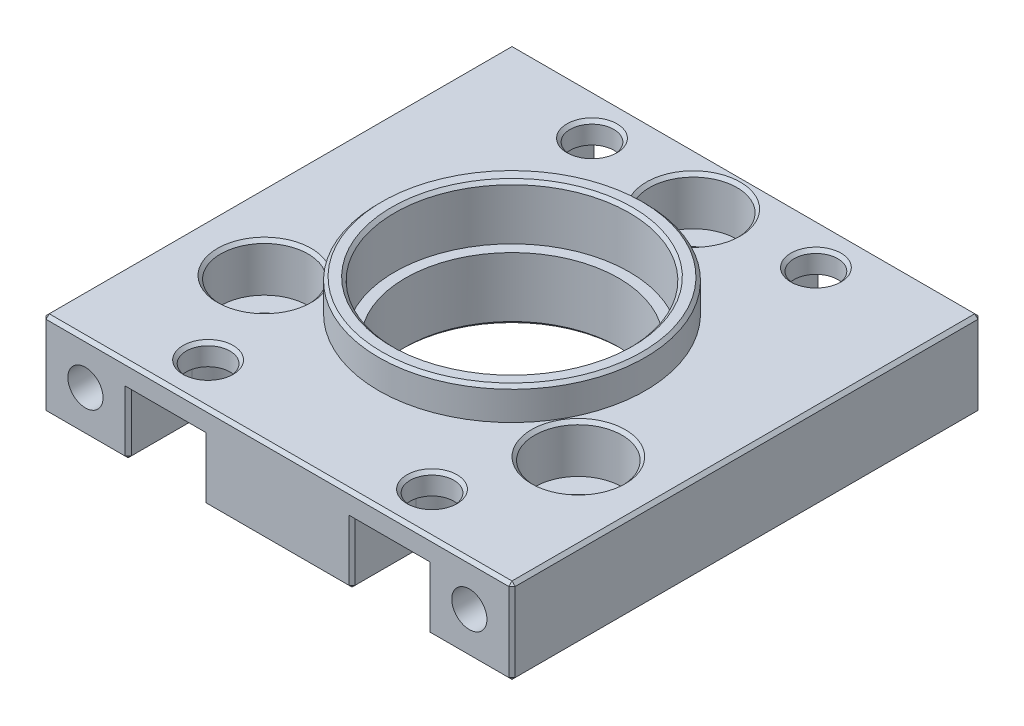
from build123d import *

# Parameters (mm, degrees)
SKETCH1_W                      = 44
SKETCH1_H                      = 44
SKETCH1_R                      = 2.05
SKETCH1_R_2                    = 10
BOSS_EXTRUDE1_DEPTH            = 5.5
SKETCH3_R                      = 11
CUT_EXTRUDE1_DEPTH             = 5.1
M4X0_7_TAPPED_HOLE1_AT_2_COUNT = 2
M4X0_7_TAPPED_HOLE1_AT_2_PITCH = 36
SKETCH6_R                      = 4.1
CUT_EXTRUDE2_DEPTH             = 7.5
SKETCH7_W                      = 44
SKETCH7_H                      = 44
SKETCH7_R                      = 12.5
SKETCH7_R_2                    = 4.1
CUT_EXTRUDE3_DEPTH             = 3
CUT_EXTRUDE_1_DEPTH            = 6
SKETCH_2_R                     = 2.05
CUT_EXTRUDE_2_DEPTH            = 5
CHAMFER_1_SIZE                 = 0.3


with BuildPart() as part:
    # Sketch1 → Boss-Extrude1 (new body, symmetric)
    with BuildSketch(Plane(origin=(0, 0, 0), x_dir=(1, 0, 0), z_dir=(0, 1, 0))):
        Rectangle(SKETCH1_W, SKETCH1_H)
        with Locations((0, 17)):
            Circle(SKETCH1_R, mode=Mode.SUBTRACT)
        with Locations((14.722431864, -8.5)):
            Circle(SKETCH1_R, mode=Mode.SUBTRACT)
        with Locations((-14.722431864, -8.5)):
            Circle(SKETCH1_R, mode=Mode.SUBTRACT)
        Circle(SKETCH1_R_2, mode=Mode.SUBTRACT)
    extrude(amount=BOSS_EXTRUDE1_DEPTH, both=True)

    # Sketch3 → Cut-Extrude1 (cut)
    with BuildSketch(Plane(origin=(0, 5.5, 0), x_dir=(1, 0, 0), z_dir=(0, 1, 0))):
        Circle(SKETCH3_R)
    extrude(amount=-CUT_EXTRUDE1_DEPTH, mode=Mode.SUBTRACT)

    # Sketch5 → M4x0.7 Tapped Hole1 (revolve, cut)
    with BuildSketch(Plane(origin=(-18, -1.5, -22), x_dir=(0, 1, 0), z_dir=(1, 0, 0))):
        Polygon((0, 0), (0, 7.991420021), (1.65, 7), (1.65, 0), align=None)
    m4x0_7_tapped_hole1 = revolve(axis=Axis((-18, -1.5, -28.35), (0, 0, 1)), mode=Mode.SUBTRACT)

    # M4x0.7 Tapped Hole1 at 2: M4x0.7 Tapped Hole1 ×2
    with Locations(*[(i * M4X0_7_TAPPED_HOLE1_AT_2_PITCH, 0, 0) for i in range(1, M4X0_7_TAPPED_HOLE1_AT_2_COUNT)]):
        add(m4x0_7_tapped_hole1, mode=Mode.SUBTRACT)

    # Mirror1: M4x0.7 Tapped Hole1 across plane
    add(m4x0_7_tapped_hole1.mirror(Plane.XY), mode=Mode.SUBTRACT)

    # Mirror1 copy 1 sketch → Mirror1 copy 1 (revolve, cut)
    with BuildSketch(Plane(origin=(18, -1.5, 22), x_dir=(0, 1, 0), z_dir=(1, 0, 0))):
        Polygon((0, 0), (0, -7.991420021), (1.65, -7), (1.65, 0), align=None)
    revolve(axis=Axis((18, -1.5, 28.35), (0, 0, 1)), mode=Mode.SUBTRACT)

    # Sketch6 → Cut-Extrude2 (cut)
    with BuildSketch(Plane(origin=(0, 5.5, 0), x_dir=(1, 0, 0), z_dir=(0, 1, 0))):
        with Locations((-14.722431864, -8.5)):
            Circle(SKETCH6_R)
        with Locations((0, 17)):
            Circle(SKETCH6_R)
        with Locations((14.722431864, -8.5)):
            Circle(SKETCH6_R)
    extrude(amount=-CUT_EXTRUDE2_DEPTH, mode=Mode.SUBTRACT)

    # Sketch7 → Cut-Extrude3 (cut)
    with BuildSketch(Plane(origin=(0, 5.5, 0), x_dir=(1, 0, 0), z_dir=(0, 1, 0))):
        Rectangle(SKETCH7_W, SKETCH7_H)
        Circle(SKETCH7_R, mode=Mode.SUBTRACT)
        with Locations((14.722431864, -8.5)):
            Circle(SKETCH7_R_2, mode=Mode.SUBTRACT)
        with Locations((0, 17)):
            Circle(SKETCH7_R_2, mode=Mode.SUBTRACT)
        with Locations((-14.722431864, -8.5)):
            Circle(SKETCH7_R_2, mode=Mode.SUBTRACT)
    extrude(amount=-CUT_EXTRUDE3_DEPTH, mode=Mode.SUBTRACT)

    # 草图1 → 切除-拉伸1 (cut)
    with BuildSketch(Plane.XZ.offset(5.5)):
        with BuildLine():
            Line((7, -36), (7, -16))
            ThreePointArc((7, -16), (10.5, -12.5), (14, -16))
            Line((14, -16), (14, -36))
            ThreePointArc((14, -36), (10.5, -39.5), (7, -36))
        make_face()
        with BuildLine():
            Line((-7, -36), (-7, -16))
            ThreePointArc((-7, -16), (-10.5, -12.5), (-14, -16))
            Line((-14, -16), (-14, -36))
            ThreePointArc((-14, -36), (-10.5, -39.5), (-7, -36))
        make_face()
        with BuildLine():
            Line((-7, 36), (-7, 16))
            ThreePointArc((-7, 16), (-10.5, 12.5), (-14, 16))
            Line((-14, 16), (-14, 36))
            ThreePointArc((-14, 36), (-10.5, 39.5), (-7, 36))
        make_face()
        with BuildLine():
            Line((7, 36), (7, 16))
            ThreePointArc((7, 16), (10.5, 12.5), (14, 16))
            Line((14, 16), (14, 36))
            ThreePointArc((14, 36), (10.5, 39.5), (7, 36))
        make_face()
    extrude(amount=-CUT_EXTRUDE_1_DEPTH, mode=Mode.SUBTRACT)

    # 草图2 → 切除-拉伸2 (cut)
    with BuildSketch(Plane.XZ.offset(-0.5)):
        with Locations((10.5, 18)):
            Circle(SKETCH_2_R)
        with Locations((-10.5, 18)):
            Circle(SKETCH_2_R)
        with Locations((-10.5, -18)):
            Circle(SKETCH_2_R)
        with Locations((10.5, -18)):
            Circle(SKETCH_2_R)
    extrude(amount=-CUT_EXTRUDE_2_DEPTH, mode=Mode.SUBTRACT)

    # 倒角1
    chamfer_1_edges = [part.edges().sort_by_distance(p)[0] for p in [
        (0, -5.5, 22),
        (18, -5.5, 22),
        (0, -5.5, -22),
        (-18, -5.5, -22),
        (14, -5.5, -19),
        (-7, -5.5, -19),
        (-14, -5.5, 19),
        (7, -5.5, 19),
        (10.5, -5.5, 12.5),
        (14, -5.5, 19),
        (14, -2.5, 22),
        (7, -2.5, 22),
        (-7, -5.5, 19),
        (-10, -5.5, 0),
        (-10.5, -5.5, 12.5),
        (-7, -2.5, 22),
        (-14, -2.5, 22),
        (-10.5, -5.5, -12.5),
        (-14, -5.5, -19),
        (-14, -2.5, -22),
        (-7, -2.5, -22),
        (7, -5.5, -19),
        (10.5, -5.5, -12.5),
        (7, -2.5, -22),
        (14, -2.5, -22),
        (-2.05, -5.5, -17),
        (8.45, 2.5, -18),
        (-12.55, 2.5, -18),
        (-12.55, 2.5, 18),
        (8.45, 2.5, 18),
        (12.672431864, -5.5, 8.5),
        (-16.772431864, -5.5, 8.5),
        (-11, 5.5, 0),
        (-18, -5.5, 22),
        (-22, -5.5, 0),
        (18, -5.5, -22),
        (22, -5.5, 0),
        (22, -1.5, 22),
        (-22, -1.5, 22),
        (-22, -1.5, -22),
        (22, -1.5, -22),
        (0, 2.5, 22),
        (-22, 2.5, 0),
        (0, 2.5, -22),
        (-4.1, 2.5, -17),
        (22, 2.5, 0),
        (10.622431864, 2.5, 8.5),
        (-12.5, 5.5, 0),
        (-18.822431864, 2.5, 8.5),
    ]]
    chamfer(chamfer_1_edges, length=CHAMFER_1_SIZE)


solid = part.part
